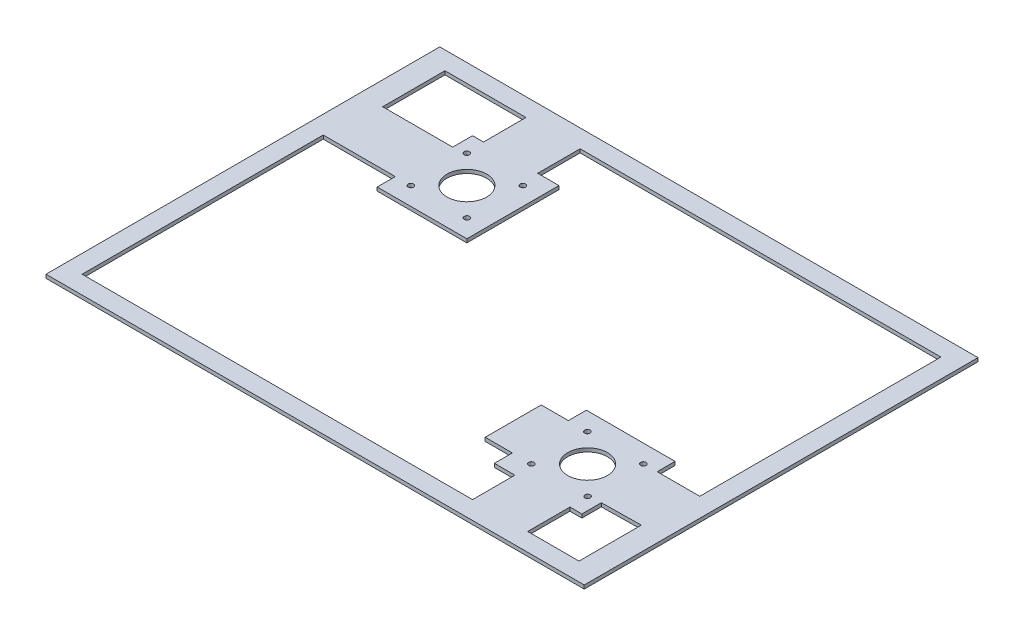
from build123d import *

# Parameters (mm, degrees)
SKETCH1_W           = 218
SKETCH1_H           = 2
BOSS_EXTRUDE1_DEPTH = 298
SKETCH2_R           = 11
SKETCH2_R_2         = 1.5
CUT_EXTRUDE1_DEPTH  = 10


with BuildPart() as part:
    # Sketch1 → Boss-Extrude1 (new body)
    with BuildSketch(Plane(origin=(0, 0, 0), x_dir=(0, 0, -1), z_dir=(1, 0, 0))):
        with Locations((82.3216851, 1)):
            Rectangle(SKETCH1_W, SKETCH1_H)
    extrude(amount=BOSS_EXTRUDE1_DEPTH)

    # Sketch2 → Cut-Extrude1 (cut)
    with BuildSketch(Plane(origin=(0, 2, 0), x_dir=(1, 0, 0), z_dir=(0, 1, 0))):
        with Locations((74, 132.3216851)):
            Circle(SKETCH2_R)
        with Locations((89.5, 116.8216851)):
            Circle(SKETCH2_R_2)
        with Locations((58.5, 116.8216851)):
            Circle(SKETCH2_R_2)
        with Locations((89.5, 147.8216851)):
            Circle(SKETCH2_R_2)
        with Locations((58.5, 147.8216851)):
            Circle(SKETCH2_R_2)
        with Locations((256.33130124, 47.719426297)):
            Circle(SKETCH2_R_2)
        with Locations((256.457517214, 16.719426297)):
            Circle(SKETCH2_R_2)
        with Locations((225.33130124, 16.719426297)):
            Circle(SKETCH2_R_2)
        with Locations((225.33130124, 47.719426297)):
            Circle(SKETCH2_R_2)
        with Locations((240.957517214, 32.219426297)):
            Circle(SKETCH2_R)
        Polygon((12.887616176, 181.3216851), (57.721228679, 181.3216851), (57.721228679, 157.8216851), (51.65209525, 157.8216851), (51.65209525, 146.8216851), (12.887616176, 146.8216851), (12.887616176, 159.517007057), align=None)
        Polygon((149, -16.6783149), (104.471210326, -16.6783149), (10, -16.6783149), (10, 89.941809838), (10, 116.8216851), (49.873323929, 116.8216851), (49.873323929, 106.8216851), (99.5, 106.8216851), (99.5, 157.8216851), (87.721228679, 157.8216851), (87.721228679, 181.3216851), (101.200621078, 181.3216851), (149, 181.3216851), (287.459100292, 181.3216851), (287.459100292, 47.8216851), (263.876177895, 47.8216851), (263.876177895, 57.719426297), (214.790401532, 57.719426297), (214.790401532, 47.719426297), (199.762615123, 47.719426297), (199.762615123, 16.719426297), (214.790401532, 16.719426297), (214.790401532, 6.77711424), (226.154489119, 6.77711424), (226.154489119, -16.6783149), align=None)
        Polygon((285.112383824, -16.6783149), (285.112383824, 5.126363143), (285.112383824, 17.8216851), (263.305421964, 17.488619524), (263.305421964, 6.719426297), (256.695388827, 6.719426297), (256.695388827, -16.6783149), align=None)
    extrude(amount=-CUT_EXTRUDE1_DEPTH, mode=Mode.SUBTRACT)


solid = part.part
